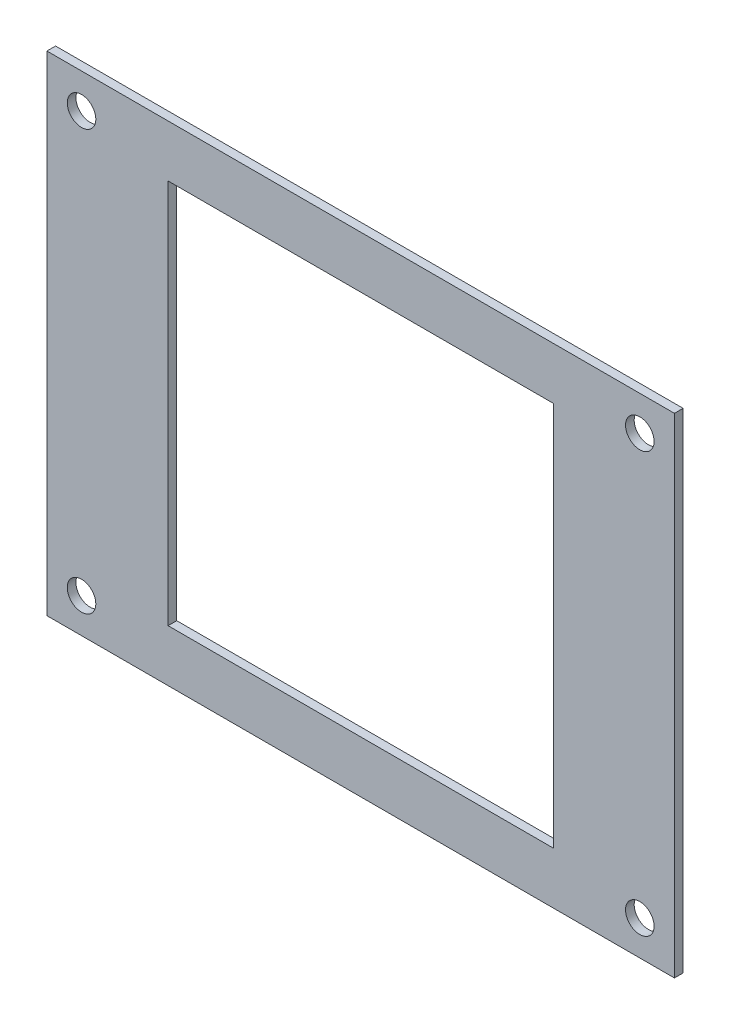
from build123d import *

# Parameters (mm, degrees)
SKETCH1_W           = 56.5
SKETCH1_H           = 72.5
SKETCH1_R           = 1.65
SKETCH1_W_2         = 44.5
SKETCH1_H_2         = 44.5
BOSS_EXTRUDE1_DEPTH = 1


with BuildPart() as part:
    # Sketch1 → Boss-Extrude1 (new body)
    with BuildSketch(Plane(origin=(0, 0, 0), x_dir=(0, 1, 0), z_dir=(0, 0, 1))):
        with Locations((28.25, 36.25)):
            Rectangle(SKETCH1_W, SKETCH1_H)
        with Locations((4, 68.5)):
            Circle(SKETCH1_R, mode=Mode.SUBTRACT)
        with Locations((52.5, 68.5)):
            Circle(SKETCH1_R, mode=Mode.SUBTRACT)
        with Locations((52.5, 4)):
            Circle(SKETCH1_R, mode=Mode.SUBTRACT)
        with Locations((4, 4)):
            Circle(SKETCH1_R, mode=Mode.SUBTRACT)
        with Locations((28.25, 36.25)):
            Rectangle(SKETCH1_W_2, SKETCH1_H_2, mode=Mode.SUBTRACT)
    extrude(amount=BOSS_EXTRUDE1_DEPTH)


solid = part.part
